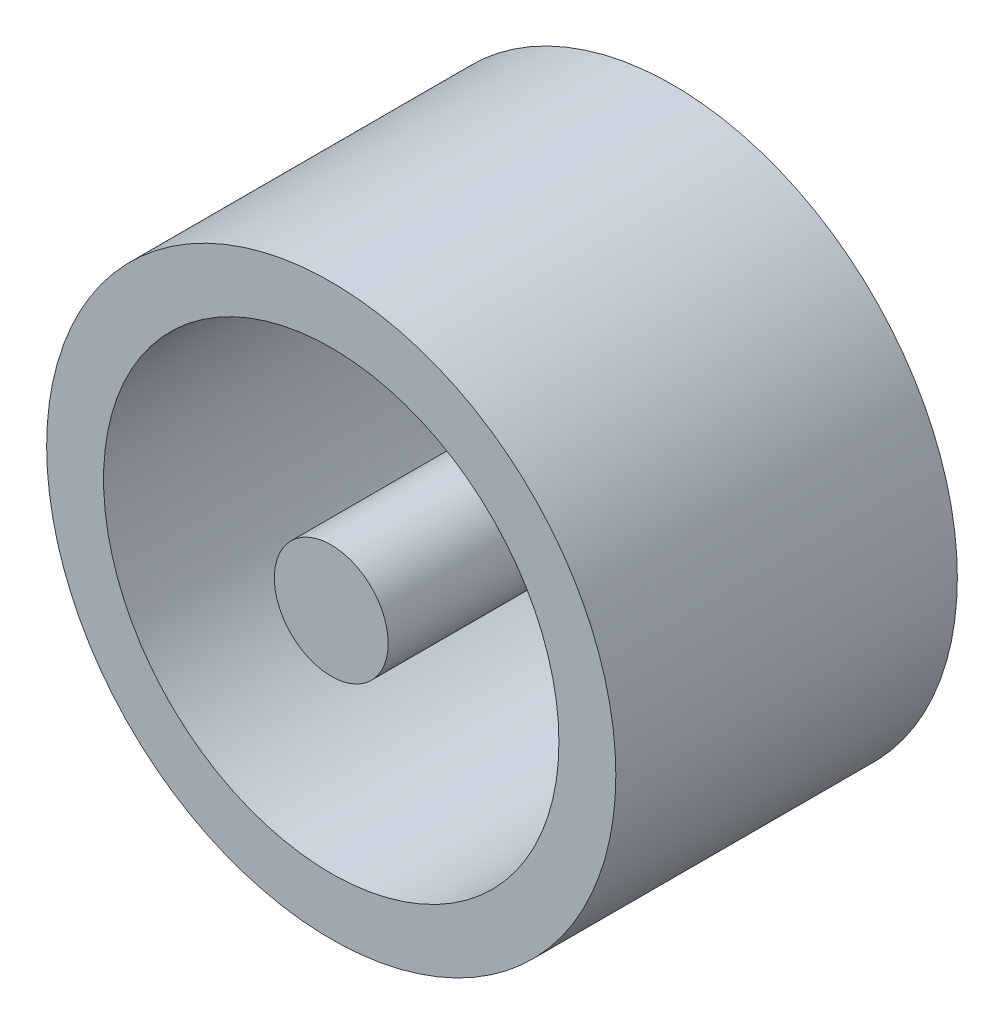
from build123d import *

# Parameters (mm, degrees)
ESQUISSE1_R        = 1.25
ESQUISSE1_R_2      = 1
BOSS_EXTRU_1_DEPTH = 1.5
ESQUISSE2_R        = 0.25
BOSS_EXTRU_2_DEPTH = 1.5


with BuildPart() as part:
    # Esquisse1 → Boss.-Extru.1 (new body)
    with BuildSketch(Plane.XY):
        Circle(ESQUISSE1_R)
        Circle(ESQUISSE1_R_2, mode=Mode.SUBTRACT)
    extrude(amount=BOSS_EXTRU_1_DEPTH)


with BuildPart() as body_2:
    # Esquisse2 → Boss.-Extru.2 (new body)
    with BuildSketch(Plane.XY):
        Circle(ESQUISSE2_R)
    extrude(amount=BOSS_EXTRU_2_DEPTH)


solid = Compound([part.part, body_2.part])
